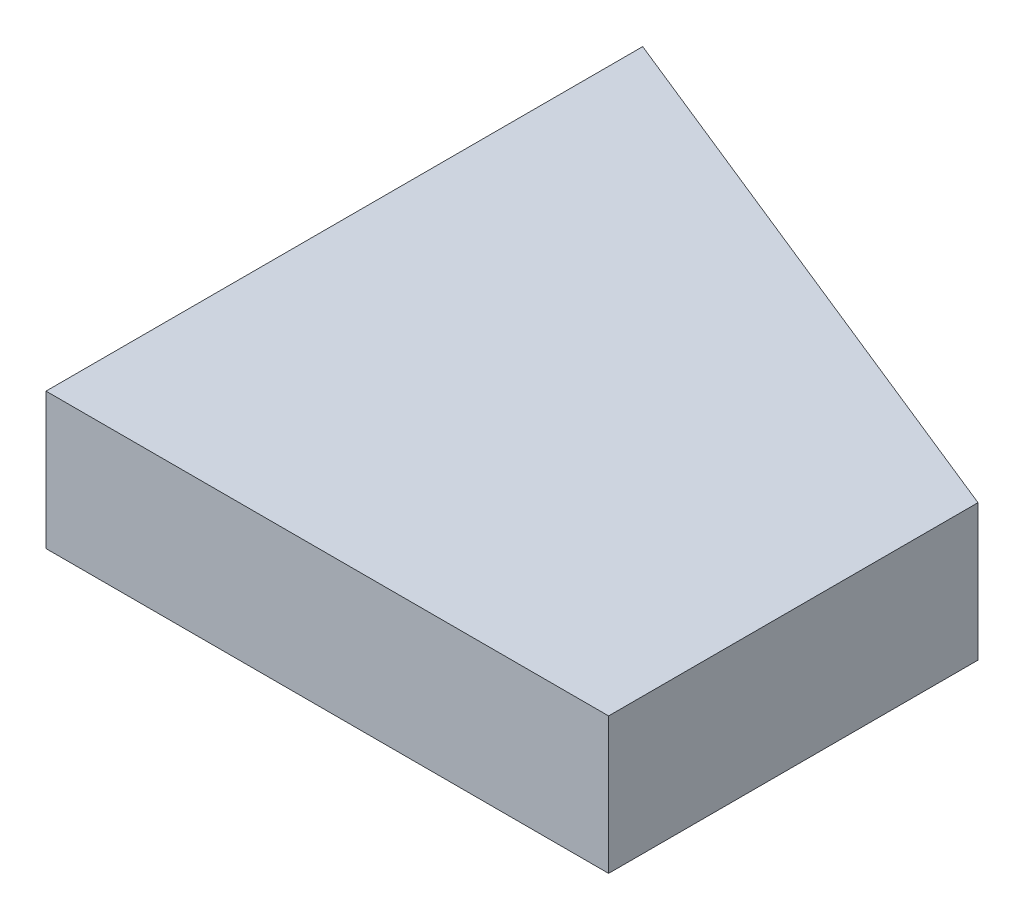
from build123d import *

# Parameters (mm, degrees)
BOSS_EXTRUDE2_DEPTH = 8
SKETCH2_R           = 1.5
CUT_EXTRUDE1_DEPTH  = 20


with BuildPart() as part:
    # Sketch1 → Boss-Extrude2 (new body)
    with BuildSketch(Plane(origin=(0, 0, 0), x_dir=(1, 0, 0), z_dir=(0, 1, 0))):
        Polygon((0, 0), (33, 0), (33, 21.667134547), (0, 35), align=None)
    extrude(amount=BOSS_EXTRUDE2_DEPTH)

    # Sketch2 → Cut-Extrude1 (cut)
    with BuildSketch(Plane(origin=(0, 0, 0), x_dir=(0, 0, -1), z_dir=(1, 0, 0))):
        with Locations((17.5, 4)):
            Circle(SKETCH2_R)
    extrude(amount=CUT_EXTRUDE1_DEPTH, mode=Mode.SUBTRACT)


solid = part.part
